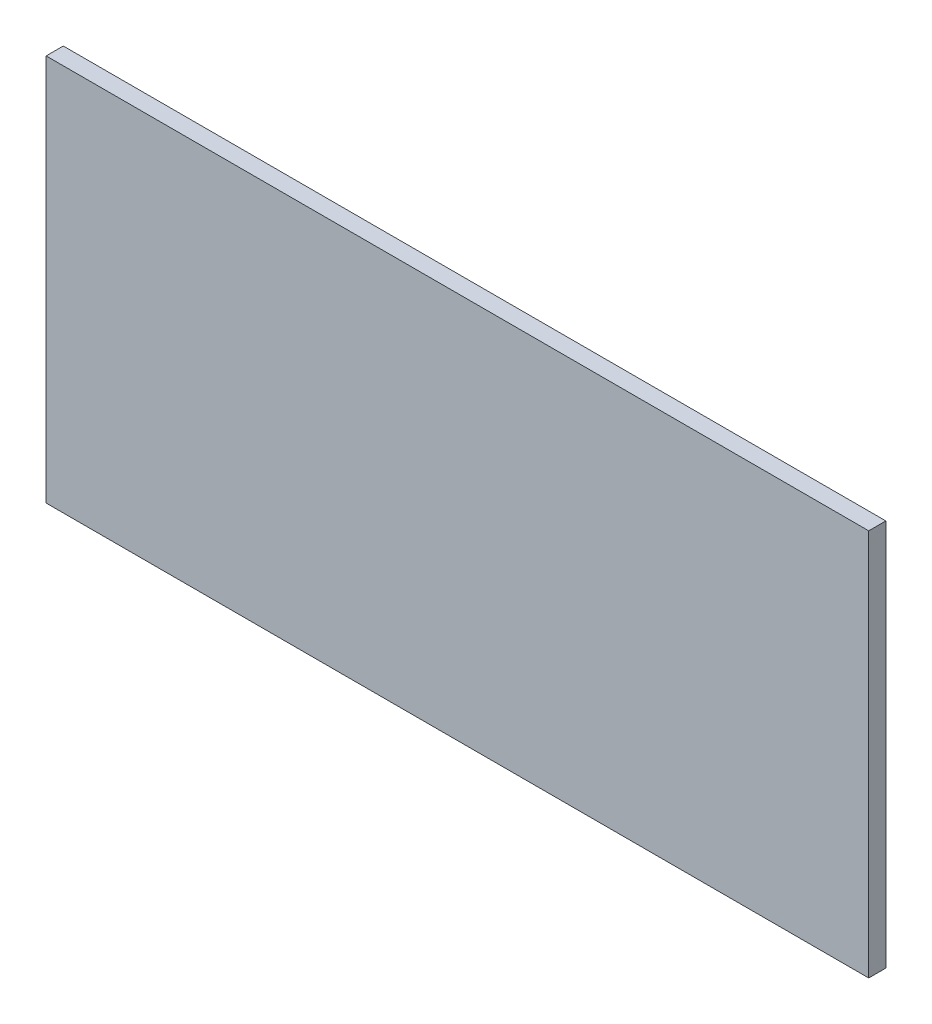
from build123d import *

# Parameters (mm, degrees)
SKETCH1_W           = 1219.2
SKETCH1_H           = 25.4
BOSS_EXTRUDE1_DEPTH = 574


with BuildPart() as part:
    # Sketch1 → Boss-Extrude1 (new body)
    with BuildSketch(Plane(origin=(0, 0, 0), x_dir=(1, 0, 0), z_dir=(0, 1, 0))):
        with Locations((609.6, 12.7)):
            Rectangle(SKETCH1_W, SKETCH1_H)
    extrude(amount=BOSS_EXTRUDE1_DEPTH)


solid = part.part
